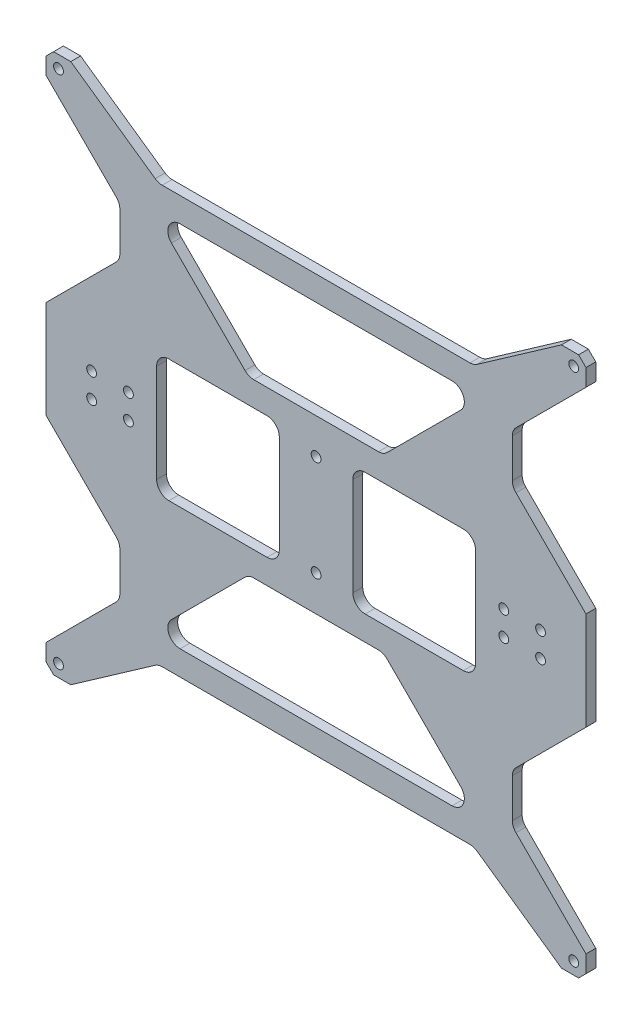
from build123d import *

# Parameters (mm, degrees)
ESQUISSE1_W             = 220
ESQUISSE1_H             = 220
ESQUISSE1_R             = 2
BOSS_EXTRU_1_DEPTH      = 4
ESQUISSE2_W             = 50
ESQUISSE2_H             = 50
ENL_V_MAT_EXTRU_1_DEPTH = 5
CONG_1_R                = 5
CHANFREIN1_SIZE         = 3
CONG_2_R                = 5


with BuildPart() as part:
    # Esquisse1 → Boss.-Extru.1 (new body)
    with BuildSketch(Plane.XY):
        with Locations((-21.875157945, -21.770833333)):
            Rectangle(ESQUISSE1_W, ESQUISSE1_H)
        with Locations((-126.875157945, 83.229166667)):
            Circle(ESQUISSE1_R, mode=Mode.SUBTRACT)
        with Locations((83.124842055, 83.229166667)):
            Circle(ESQUISSE1_R, mode=Mode.SUBTRACT)
        with Locations((-126.875157945, -126.770833333)):
            Circle(ESQUISSE1_R, mode=Mode.SUBTRACT)
        with Locations((83.124842055, -126.770833333)):
            Circle(ESQUISSE1_R, mode=Mode.SUBTRACT)
        with Locations((-113.375157945, -16.770833333)):
            Circle(ESQUISSE1_R, mode=Mode.SUBTRACT)
        with Locations((-98.375157945, -16.770833333)):
            Circle(ESQUISSE1_R, mode=Mode.SUBTRACT)
        with Locations((-113.375157945, -26.770833333)):
            Circle(ESQUISSE1_R, mode=Mode.SUBTRACT)
        with Locations((-98.375157945, -26.770833333)):
            Circle(ESQUISSE1_R, mode=Mode.SUBTRACT)
        with Locations((54.624842055, -16.770833333)):
            Circle(ESQUISSE1_R, mode=Mode.SUBTRACT)
        with Locations((69.624842055, -16.770833333)):
            Circle(ESQUISSE1_R, mode=Mode.SUBTRACT)
        with Locations((54.624842055, -26.770833333)):
            Circle(ESQUISSE1_R, mode=Mode.SUBTRACT)
        with Locations((69.624842055, -26.770833333)):
            Circle(ESQUISSE1_R, mode=Mode.SUBTRACT)
        with Locations((-21.875157945, -1.270833333)):
            Circle(ESQUISSE1_R, mode=Mode.SUBTRACT)
        with Locations((-21.875157945, -42.270833333)):
            Circle(ESQUISSE1_R, mode=Mode.SUBTRACT)
    extrude(amount=BOSS_EXTRU_1_DEPTH)

    # Esquisse2 → Enlèv. mat.-Extru.1 (cut, through all)
    with BuildSketch(Plane.XY.offset(4)):
        Polygon((-89.375157945, 53.229166667), (45.624842055, 53.229166667), (5.624842055, 13.229166667), (-49.375157945, 13.229166667), align=None)
        Polygon((-89.375157945, -96.770833333), (45.624842055, -96.770833333), (5.624842055, -56.770833333), (-49.375157945, -56.770833333), align=None)
        Polygon((88.124842055, -41.770833333), (58.124842055, -71.770833333), (58.124842055, -91.770833333), (88.124842055, -121.770833333), align=None)
        Polygon((88.124842055, 78.229166667), (88.124842055, -1.770833333), (58.124842055, 28.229166667), (58.124842055, 48.229166667), align=None)
        Polygon((-131.875157945, 78.229166667), (-131.875157945, -1.770833333), (-101.875157945, 28.229166667), (-101.875157945, 48.229166667), align=None)
        Polygon((-131.875157945, -41.770833333), (-101.875157945, -71.770833333), (-101.875157945, -91.770833333), (-131.875157945, -121.770833333), align=None)
        with Locations((18.124842055, -21.770833333)):
            Rectangle(ESQUISSE2_W, ESQUISSE2_H)
        with Locations((-61.875157945, -21.770833333)):
            Rectangle(ESQUISSE2_W, ESQUISSE2_H)
        Polygon((-121.875157945, -131.770833333), (-86.171457776, -106.770833333), (42.421141887, -106.770833333), (78.124842055, -131.770833333), align=None)
        Polygon((-121.875157945, 88.229166667), (-86.171457776, 63.229166667), (42.421141887, 63.229166667), (78.124842055, 88.229166667), align=None)
    extrude(amount=-ENL_V_MAT_EXTRU_1_DEPTH, mode=Mode.SUBTRACT)

    # Congé1
    cong_1_edges = [part.edges().sort_by_distance(p)[0] for p in [
        (-89.375157945, 53.229166667, 2),
        (45.624842055, 53.229166667, 2),
        (-89.375157945, -96.770833333, 2),
        (45.624842055, -96.770833333, 2),
    ]]
    fillet(cong_1_edges, radius=CONG_1_R)

    # Chanfrein1
    chanfrein1_edges = [part.edges().sort_by_distance(p)[0] for p in [
        (-131.875157945, 88.229166667, 2),
        (88.124842055, 88.229166667, 2),
        (88.124842055, -131.770833333, 2),
        (-131.875157945, -131.770833333, 2),
    ]]
    chamfer(chanfrein1_edges, length=CHANFREIN1_SIZE)

    # Congé2
    cong_2_edges = [part.edges().sort_by_distance(p)[0] for p in [
        (58.124842055, -91.770833333, 2),
        (58.124842055, -71.770833333, 2),
        (58.124842055, 48.229166667, 2),
        (58.124842055, 28.229166667, 2),
        (-101.875157945, 48.229166667, 2),
        (-101.875157945, 28.229166667, 2),
        (-101.875157945, -71.770833333, 2),
        (-101.875157945, -91.770833333, 2),
        (-86.875157945, -46.770833333, 2),
        (-86.875157945, 3.229166667, 2),
        (-36.875157945, 3.229166667, 2),
        (-36.875157945, -46.770833333, 2),
        (-6.875157945, -46.770833333, 2),
        (-6.875157945, 3.229166667, 2),
        (43.124842055, 3.229166667, 2),
        (43.124842055, -46.770833333, 2),
        (-86.171457776, -106.770833333, 2),
        (42.421141887, -106.770833333, 2),
        (42.421141887, 63.229166667, 2),
        (-86.171457776, 63.229166667, 2),
        (-49.375157945, 13.229166667, 2),
        (5.624842055, 13.229166667, 2),
        (-49.375157945, -56.770833333, 2),
        (5.624842055, -56.770833333, 2),
    ]]
    fillet(cong_2_edges, radius=CONG_2_R)


solid = part.part
